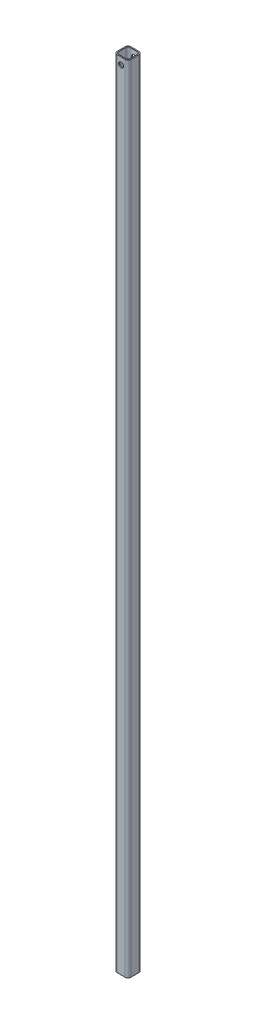
from build123d import *

# Parameters (mm, degrees)
BOSS_EXTRUDE1_DEPTH = 914.4
SKETCH2_R           = 5.715
CUT_EXTRUDE1_DEPTH  = 32.75


with BuildPart() as part:
    # Sketch1 → Boss-Extrude1 (new body, symmetric)
    with BuildSketch(Plane(origin=(0, 0, 0), x_dir=(1, 0, 0), z_dir=(0, 1, 0))):
        with BuildLine():
            Line((-9.525, -15.875), (9.525, -15.875))
            ThreePointArc((9.525, -15.875), (14.015128061, -14.015128061), (15.875, -9.525))
            Line((15.875, -9.525), (15.875, 9.525))
            ThreePointArc((15.875, 9.525), (14.015128061, 14.015128061), (9.525, 15.875))
            Line((9.525, 15.875), (-9.525, 15.875))
            ThreePointArc((-9.525, 15.875), (-14.015128061, 14.015128061), (-15.875, 9.525))
            Line((-15.875, 9.525), (-15.875, -9.525))
            ThreePointArc((-15.875, -9.525), (-14.015128061, -14.015128061), (-9.525, -15.875))
        make_face()
        with BuildLine():
            Line((-8.6995, -13.462), (8.6995, -13.462))
            ThreePointArc((8.6995, -13.462), (12.067096045, -12.067096045), (13.462, -8.6995))
            Line((13.462, -8.6995), (13.462, 8.6995))
            ThreePointArc((13.462, 8.6995), (12.067096045, 12.067096045), (8.6995, 13.462))
            Line((8.6995, 13.462), (-8.6995, 13.462))
            ThreePointArc((-8.6995, 13.462), (-12.067096045, 12.067096045), (-13.462, 8.6995))
            Line((-13.462, 8.6995), (-13.462, -8.6995))
            ThreePointArc((-13.462, -8.6995), (-12.067096045, -12.067096045), (-8.6995, -13.462))
        make_face(mode=Mode.SUBTRACT)
    extrude(amount=BOSS_EXTRUDE1_DEPTH, both=True)

    # Sketch2 → Cut-Extrude1 (cut, through all)
    with BuildSketch(Plane.XY.offset(15.875)):
        with Locations((0, 898.525)):
            Circle(SKETCH2_R)
    extrude(amount=-CUT_EXTRUDE1_DEPTH, mode=Mode.SUBTRACT)


solid = part.part
